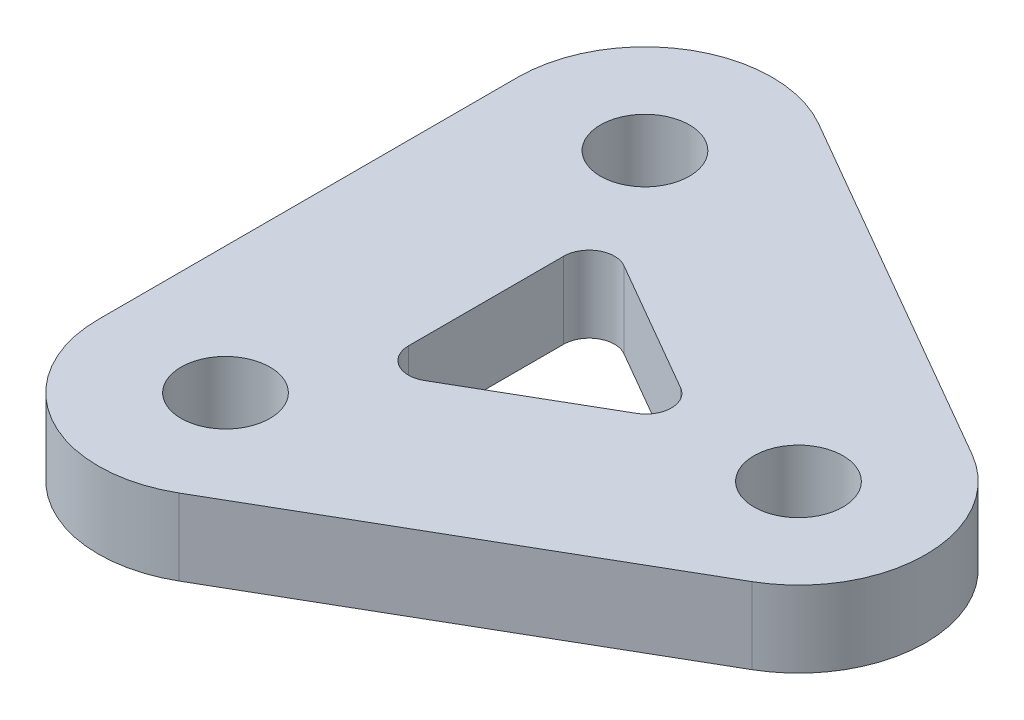
from build123d import *

# Parameters (mm, degrees)
SKETCH3_R           = 1.75
BOSS_EXTRUDE1_DEPTH = 3


with BuildPart() as part:
    # Sketch3 → Boss-Extrude1 (new body)
    with BuildSketch(Plane(origin=(0, 0, 0), x_dir=(1, 0, 0), z_dir=(0, 1, 0))):
        with BuildLine():
            Line((9.644709581, 4.330127019), (-4.644709581, 12.580127019))
            ThreePointArc((-4.644709581, 12.580127019), (-9.644709581, 12.580127019), (-12.144709581, 8.25))
            Line((-12.144709581, 8.25), (-12.144709581, -8.25))
            ThreePointArc((-12.144709581, -8.25), (-9.644709581, -12.580127019), (-4.644709581, -12.580127019))
            Line((-4.644709581, -12.580127019), (9.644709581, -4.330127019))
            ThreePointArc((9.644709581, -4.330127019), (12.144709581, 0), (9.644709581, 4.330127019))
        make_face()
        with Locations((7.144709581, 0)):
            Circle(SKETCH3_R, mode=Mode.SUBTRACT)
        with Locations((-7.144709581, 8.25)):
            Circle(SKETCH3_R, mode=Mode.SUBTRACT)
        with Locations((-7.144709581, -8.25)):
            Circle(SKETCH3_R, mode=Mode.SUBTRACT)
        with BuildLine():
            Line((1.644709581, 0.866025404), (-3.644709581, 3.919872981))
            ThreePointArc((-3.644709581, 3.919872981), (-4.644709581, 3.919872981), (-5.144709581, 3.053847577))
            Line((-5.144709581, 3.053847577), (-5.144709581, -3.053847577))
            ThreePointArc((-5.144709581, -3.053847577), (-4.644709581, -3.919872981), (-3.644709581, -3.919872981))
            Line((-3.644709581, -3.919872981), (1.644709581, -0.866025404))
            ThreePointArc((1.644709581, -0.866025404), (2.144709581, 0), (1.644709581, 0.866025404))
        make_face(mode=Mode.SUBTRACT)
    extrude(amount=BOSS_EXTRUDE1_DEPTH)


solid = part.part
